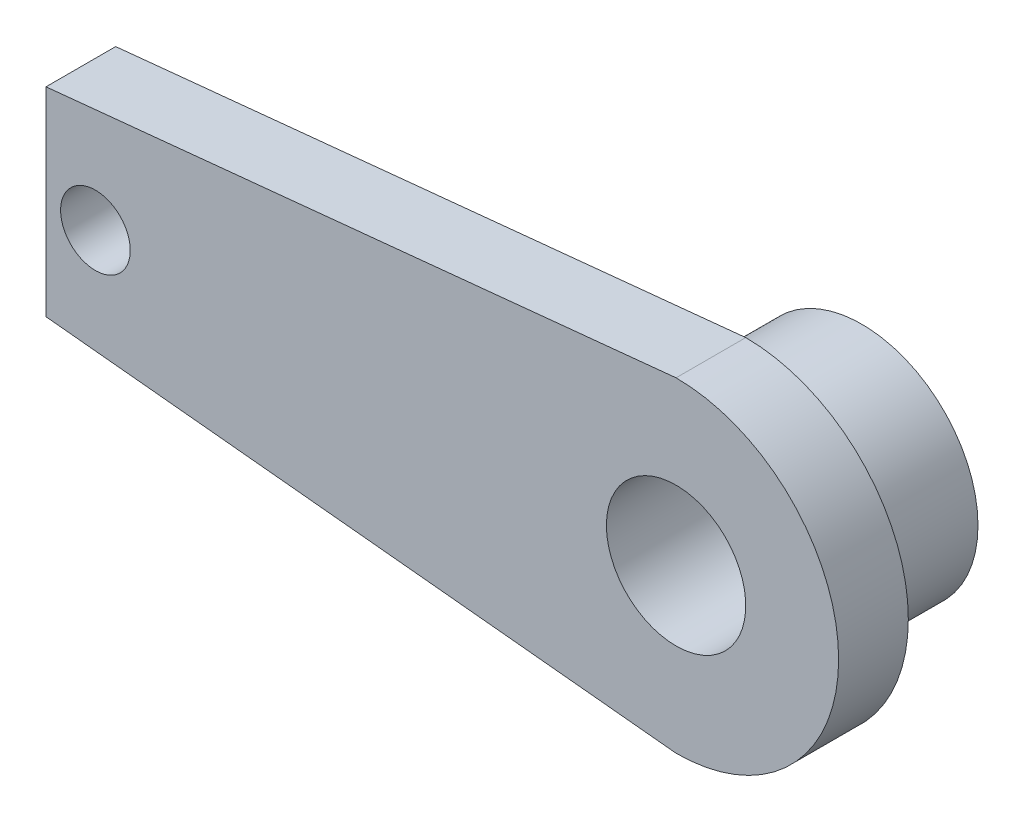
from build123d import *

# Parameters (mm, degrees)
SKETCH1_R           = 5
SKETCH1_R_2         = 3
BOSS_EXTRUDE1_DEPTH = 5
BOSS_EXTRUDE2_DEPTH = 3
SKETCH3_R           = 1.5
CUT_EXTRUDE1_DEPTH  = 3
SKETCH4_R           = 3
CUT_EXTRUDE2_DEPTH  = 3
CUT_EXTRUDE3_DEPTH  = 10


with BuildPart() as part:
    # Sketch1 → Boss-Extrude1 (new body)
    with BuildSketch(Plane.XY):
        Circle(SKETCH1_R)
        Circle(SKETCH1_R_2, mode=Mode.SUBTRACT)
    extrude(amount=BOSS_EXTRUDE1_DEPTH)

    # Sketch2 → Boss-Extrude2 (add)
    with BuildSketch(Plane.XY.offset(5)):
        with BuildLine():
            Line((-30, 4), (0, 7))
            ThreePointArc((0, 7), (7, 0), (0, -7))
            Line((0, -7), (-30, -4))
            ThreePointArc((-30, -4), (-34, 0), (-30, 4))
        make_face()
    extrude(amount=BOSS_EXTRUDE2_DEPTH)

    # Sketch3 → Cut-Extrude1 (cut)
    with BuildSketch(Plane(origin=(0, 0, 5), x_dir=(-1, 0, 0), z_dir=(0, 0, -1))):
        with Locations((25, 0)):
            Circle(SKETCH3_R)
    extrude(amount=-CUT_EXTRUDE1_DEPTH, mode=Mode.SUBTRACT)

    # Sketch4 → Cut-Extrude2 (cut)
    with BuildSketch(Plane(origin=(0, 0, 5), x_dir=(-1, 0, 0), z_dir=(0, 0, -1))):
        Circle(SKETCH4_R)
    extrude(amount=-CUT_EXTRUDE2_DEPTH, mode=Mode.SUBTRACT)

    # Sketch5 → Cut-Extrude3 (cut)
    with BuildSketch(Plane(origin=(0, 0, 5), x_dir=(-1, 0, 0), z_dir=(0, 0, -1))):
        with BuildLine():
            Line((27.128027058, 4.287197294), (27.128027058, 0))
            Line((27.128027058, 0), (27.128027058, -4.287197294))
            Line((27.128027058, -4.287197294), (30, -4))
            ThreePointArc((30, -4), (34, 0), (30, 4))
            Line((30, 4), (27.128027058, 4.287197294))
        make_face()
    extrude(amount=-CUT_EXTRUDE3_DEPTH, mode=Mode.SUBTRACT)


solid = part.part
